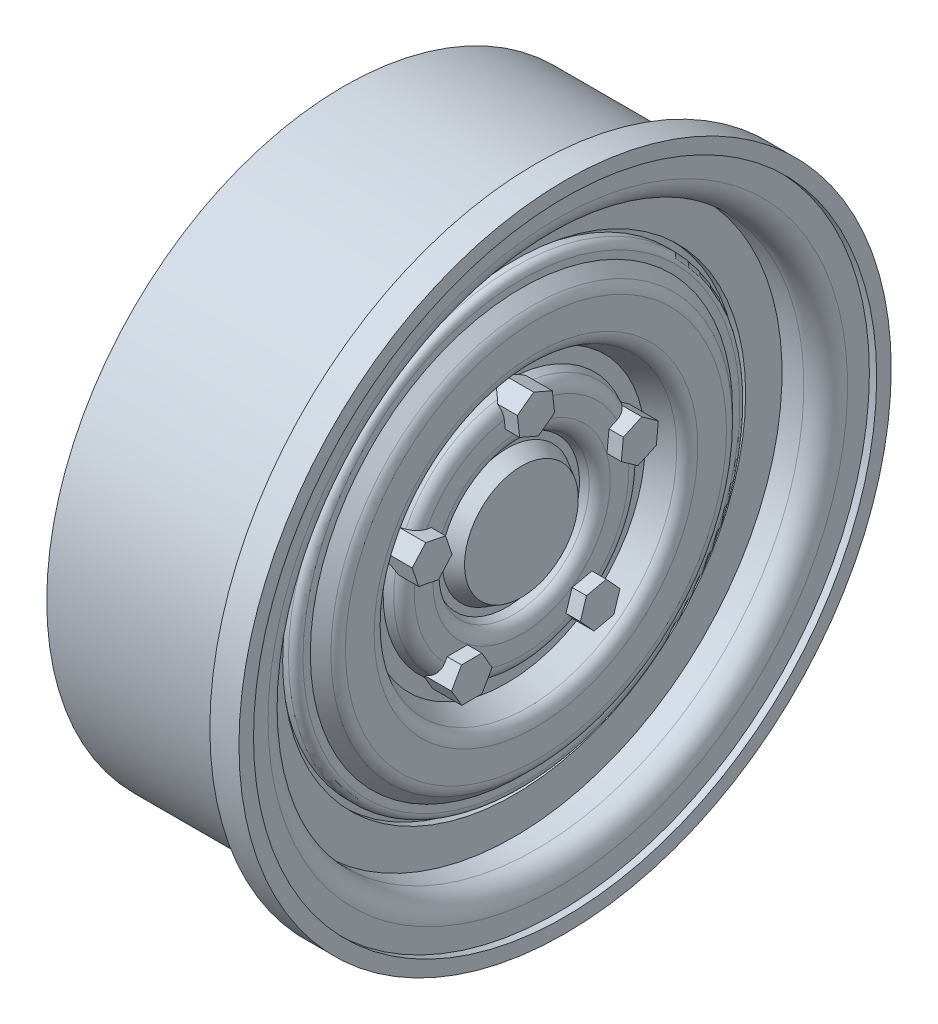
from build123d import *

# Parameters (mm, degrees)
FILLET1_R                = 0.5
FILLET2_R                = 1
FILLET3_R                = 1
BOSS_EXTRUDE1_DEPTH      = 1
BOSS_EXTRUDE1_DEPTH_BACK = 2


with BuildPart() as part:
    # Sketch1 → Revolve1 (revolve)
    with BuildSketch(Plane.XY):
        with BuildLine():
            Line((5.138480682, 22.4), (3.138480682, 22.4))
            Line((3.138480682, 22.4), (3.138480682, 20.4))
            Line((3.138480682, 20.4), (-10.061519318, 20.4))
            Line((-10.061519318, 20.4), (-10.061519318, 18.4))
            Line((-10.061519318, 18.4), (-3.598245279, 18.4))
            Line((-3.598245279, 18.4), (-3.598245279, 7.6))
            Line((-3.598245279, 7.6), (-10.061519318, 7.6))
            Line((-10.061519318, 7.6), (-10.061519318, 5.6))
            Line((-10.061519318, 5.6), (-3.598245279, 5.6))
            Line((-3.598245279, 5.6), (-3.598245279, 0))
            Line((-3.598245279, 0), (1.040301002, 0))
            Line((1.040301002, 0), (2.138480682, 0))
            Line((2.138480682, 0), (2.138480682, 3.907933456))
            Line((2.138480682, 3.907933456), (1.152358089, 4.47269746))
            Line((1.152358089, 4.47269746), (1.152358089, 4.972417174))
            Line((1.152358089, 4.972417174), (2.152358089, 5.472417174))
            Line((2.152358089, 5.472417174), (2.152358089, 7.972417174))
            Line((2.152358089, 7.972417174), (1.138480682, 8.5))
            Line((1.138480682, 8.5), (1.138480682, 9.5))
            Line((1.138480682, 9.5), (3.138480682, 10.5))
            Line((3.138480682, 10.5), (3.138480682, 13.5))
            Line((3.138480682, 13.5), (2.138480682, 14.5))
            Line((2.138480682, 14.5), (2.138480682, 15.5))
            Line((2.138480682, 15.5), (1.138480682, 15.5))
            Line((1.138480682, 15.5), (1.138480682, 15.9))
            Line((1.138480682, 15.9), (1.638480682, 15.9))
            Line((1.638480682, 15.9), (1.638480682, 18.4))
            Line((1.638480682, 18.4), (3.138480682, 18.4))
            ThreePointArc((3.138480682, 18.4), (4.199140854, 18.839339828), (4.638480682, 19.9))
            Line((4.638480682, 19.9), (4.638480682, 21.4))
            Line((4.638480682, 21.4), (5.138480682, 21.4))
            Line((5.138480682, 21.4), (5.138480682, 22.4))
        make_face()
    revolve(axis=Axis((-13.433569408, 0, 0), (1, 0, 0)))

    # Fillet1
    fillet1_edges = [part.edges().sort_by_distance(p)[0] for p in [
        (2.138480682, -15.5, 0),
    ]]
    fillet(fillet1_edges, radius=FILLET1_R)

    # Fillet2
    fillet2_edges = [part.edges().sort_by_distance(p)[0] for p in [
        (3.138480682, -10.5, 0),
        (3.138480682, -13.5, 0),
    ]]
    fillet(fillet2_edges, radius=FILLET2_R)

    # Fillet3
    fillet3_edges = [part.edges().sort_by_distance(p)[0] for p in [
        (2.152358089, -5.472417174, 0),
        (2.152358089, -7.972417174, 0),
    ]]
    fillet(fillet3_edges, radius=FILLET3_R)

    # Sketch2 → Boss-Extrude1 (add, two sides)
    with BuildSketch(Plane(origin=(2.138480682, 0, 0), x_dir=(0, 0, -1), z_dir=(1, 0, 0))) as boss_extrude1_sk:
        Polygon((6.997455497, 0.930333424), (8.26662156, 1.506661387), (8.402089935, 2.89395542), (7.268392248, 3.704921491), (5.999226184, 3.128593529), (5.863757809, 1.741299496), align=None)
        Polygon((1.277533, 6.942464486), (1.121606418, 8.327608276), (-0.155926582, 8.885143789), (-1.277533, 8.057535514), (-1.121606418, 6.672391724), (0.155926582, 6.114856211), align=None)
        Polygon((3.047132332, -6.367486809), (3.987446678, -7.396440329), (5.348703738, -7.096580978), (5.769646453, -5.767768106), (4.829332107, -4.738814587), (3.468075046, -5.038673938), align=None)
        Polygon((-5.114224148, -4.865656695), (-5.802243985, -6.077912906), (-5.096409229, -7.279883668), (-3.702554637, -7.26959822), (-3.0145348, -6.05734201), (-3.720369555, -4.855371247), align=None)
        Polygon((-6.207896681, 3.360345594), (-7.573430671, 3.640083573), (-8.498457863, 2.597365437), (-8.057951063, 1.274909322), (-6.692417073, 0.995171343), (-5.767389882, 2.037889479), align=None)
    extrude(amount=BOSS_EXTRUDE1_DEPTH)
    extrude(boss_extrude1_sk.sketch, amount=-BOSS_EXTRUDE1_DEPTH_BACK)


solid = part.part
